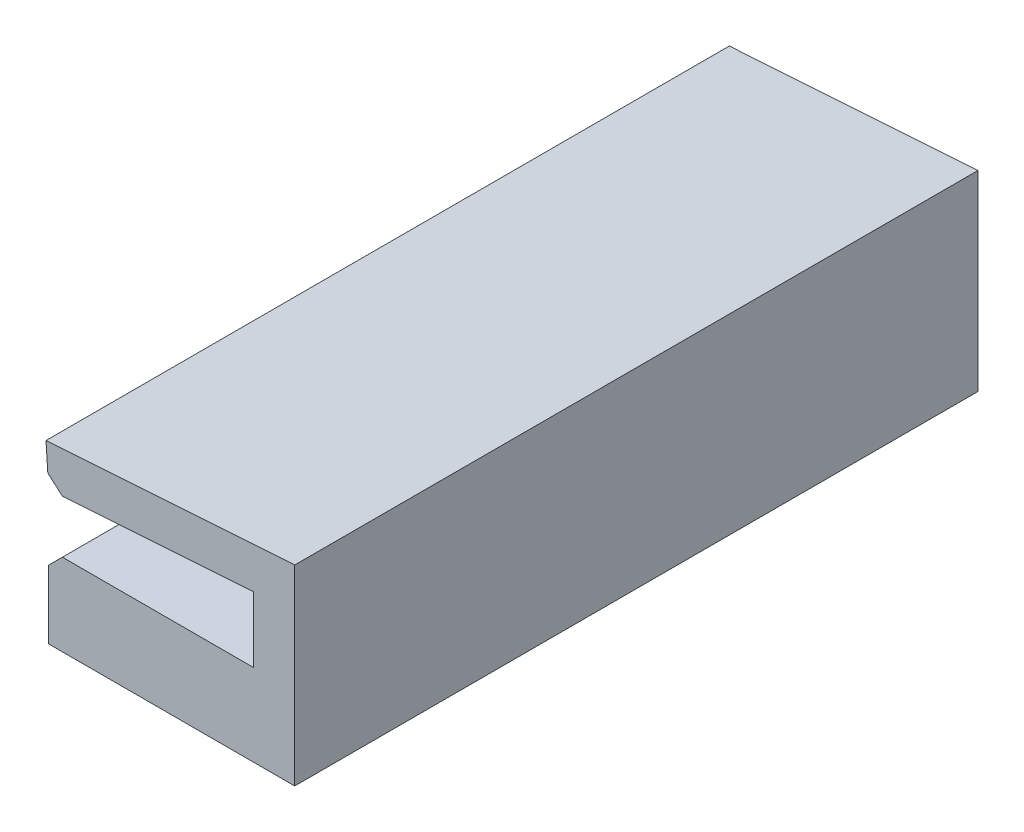
from build123d import *

# Parameters (mm, degrees)
BOSS_EXTRU_1_DEPTH = 50
ESQUISSE2_W        = 18
ESQUISSE2_H        = 50
BOSS_EXTRU_2_DEPTH = 3
CHANFREIN1_SIZE    = 1
CONG_1_R           = 0.5


with BuildPart() as part:
    # Esquisse1 → Boss.-Extru.1 (new body)
    with BuildSketch(Plane.XY):
        Polygon((0, 4.8), (0, 0), (-15, 0), (-15, -3), (3, -3), (3, 8.006659276), (-15.199557032, 6.793355474), (-15, 3.8), align=None)
    extrude(amount=BOSS_EXTRU_1_DEPTH)

    # Esquisse2 → Boss.-Extru.2 (add)
    with BuildSketch(Plane.XZ.offset(3)):
        with Locations((-6, 25)):
            Rectangle(ESQUISSE2_W, ESQUISSE2_H)
        with BuildLine():
            Line((-5.636810707, 25), (-4.842377656, 25.271173743))
            ThreePointArc((-4.842377656, 25.271173743), (-6, 33.1), (-7.157622344, 25.271173743))
            Line((-7.157622344, 25.271173743), (-6.363189293, 25))
            Line((-6.363189293, 25), (-7.157622344, 24.728826257))
            ThreePointArc((-7.157622344, 24.728826257), (-6, 16.9), (-4.842377656, 24.728826257))
            Line((-4.842377656, 24.728826257), (-5.636810707, 25))
        make_face(mode=Mode.SUBTRACT)
    extrude(amount=BOSS_EXTRU_2_DEPTH)

    # Chanfrein1
    chanfrein1_edges = [part.edges().sort_by_distance(p)[0] for p in [
        (-15, 3.8, 25),
        (-15, 0, 25),
    ]]
    chamfer(chanfrein1_edges, length=CHANFREIN1_SIZE)

    # Congé1
    cong_1_edges = [part.edges().sort_by_distance(p)[0] for p in [
        (-6.363189293, -4.5, 25),
        (-5.636810707, -4.5, 25),
    ]]
    fillet(cong_1_edges, radius=CONG_1_R)


solid = part.part
